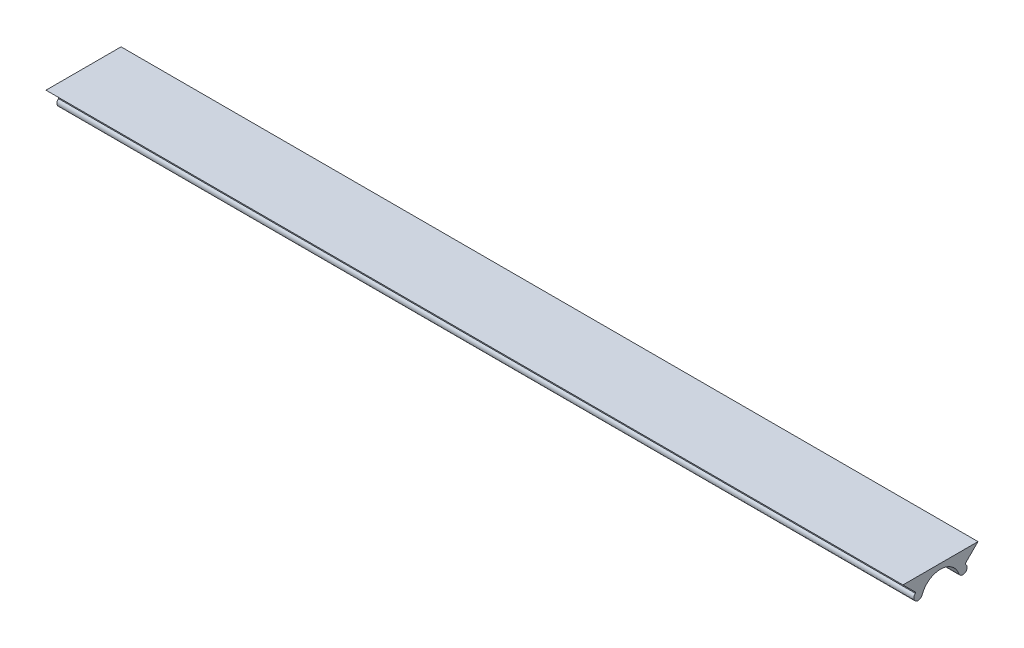
from build123d import *

# Parameters (mm, degrees)
BOSS_EXTRUDE1_DEPTH = 100


with BuildPart() as part:
    # Sketch1 → Boss-Extrude1 (new body)
    with BuildSketch(Plane(origin=(32.364284334, 0, 0), x_dir=(0, 0, -1), z_dir=(1, 0, 0))):
        with BuildLine():
            ThreePointArc((-10.800866483, 33.955059464), (-10.773935743, 33.156778763), (-10.014083429, 33.402953098))
            ThreePointArc((-10.014083429, 33.402953098), (-7.875866483, 34.92701851), (-5.737649536, 33.402953098))
            ThreePointArc((-5.737649536, 33.402953098), (-4.977797222, 33.156778763), (-4.950866483, 33.955059464))
            Line((-4.950866483, 33.955059464), (-4.950866483, 34.079201599))
            Line((-4.950866483, 34.079201599), (-3.496394261, 35.533673821))
            Line((-3.496394261, 35.533673821), (-12.255338704, 35.533673821))
            Line((-12.255338704, 35.533673821), (-10.800866483, 34.079201599))
            Line((-10.800866483, 34.079201599), (-10.800866483, 33.955059464))
        make_face()
    extrude(amount=BOSS_EXTRUDE1_DEPTH)


solid = part.part
